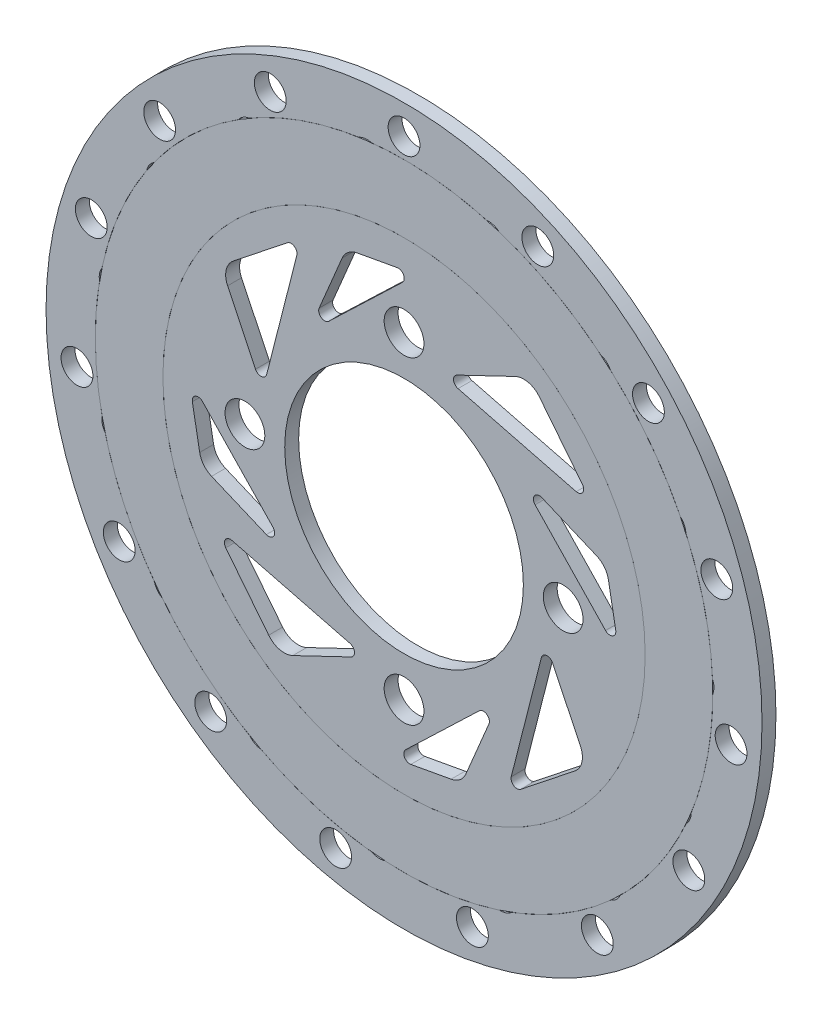
from build123d import *

# Parameters (mm, degrees)
SKETCH1_R                = 90
SKETCH1_R_2              = 30
SKETCH1_R_3              = 5
SKETCH1_R_4              = 4
SKETCH1_R_5              = 4.163878313
BOSS_EXTRUDE1_DEPTH      = 3.5
SKETCH3_R                = 77.611648898
SKETCH3_R_2              = 60.616629638
BOSS_EXTRUDE2_DEPTH      = 0.001
BOSS_EXTRUDE2_DEPTH_BACK = 3.501


with BuildPart() as part:
    # Sketch1 → Boss-Extrude1 (new body)
    with BuildSketch(Plane.XY):
        with Locations((-38.590160458, 20.233035518)):
            Circle(SKETCH1_R)
        with Locations((-38.590160458, 20.233035518)):
            Circle(SKETCH1_R_2, mode=Mode.SUBTRACT)
        with Locations((-38.590160458, 60.233035518)):
            Circle(SKETCH1_R_3, mode=Mode.SUBTRACT)
        with Locations((-78.590160458, 20.233035518)):
            Circle(SKETCH1_R_3, mode=Mode.SUBTRACT)
        with Locations((-38.590160458, -19.766964482)):
            Circle(SKETCH1_R_3, mode=Mode.SUBTRACT)
        with Locations((1.409839542, 20.233035518)):
            Circle(SKETCH1_R_3, mode=Mode.SUBTRACT)
        with Locations((-38.590160458, 102.908863271)):
            Circle(SKETCH1_R_4, mode=Mode.SUBTRACT)
        with Locations((-57.272235988, 84.226787741)):
            Circle(SKETCH1_R_5, mode=Mode.SUBTRACT)
        with Locations((-47.931198223, 93.567825506)):
            Circle(SKETCH1_R_4, mode=Mode.SUBTRACT)
        with Locations((-29.628481741, 86.292921865)):
            Circle(SKETCH1_R_5, mode=Mode.SUBTRACT)
        with Locations((-17.295676778, 91.027042142)):
            Circle(SKETCH1_R_4, mode=Mode.SUBTRACT)
        with Locations((-4.962871814, 95.761162419)):
            Circle(SKETCH1_R_4, mode=Mode.SUBTRACT)
        with Locations((-3.534283159, 76.936701505)):
            Circle(SKETCH1_R_5, mode=Mode.SUBTRACT)
        with Locations((9.657834985, 76.24533189)):
            Circle(SKETCH1_R_4, mode=Mode.SUBTRACT)
        with Locations((22.849953128, 75.553962274)):
            Circle(SKETCH1_R_4, mode=Mode.SUBTRACT)
        with Locations((16.498435766, 57.77590216)):
            Circle(SKETCH1_R_5, mode=Mode.SUBTRACT)
        with Locations((28.268830016, 51.778586739)):
            Circle(SKETCH1_R_4, mode=Mode.SUBTRACT)
        with Locations((40.039224266, 45.781271318)):
            Circle(SKETCH1_R_4, mode=Mode.SUBTRACT)
        with Locations((27.00583594, 32.123600105)):
            Circle(SKETCH1_R_5, mode=Mode.SUBTRACT)
        with Locations((35.3192982, 21.857329199)):
            Circle(SKETCH1_R_4, mode=Mode.SUBTRACT)
        with Locations((43.63276046, 11.591058294)):
            Circle(SKETCH1_R_4, mode=Mode.SUBTRACT)
        with Locations((26.171092415, 4.415311411)):
            Circle(SKETCH1_R_5, mode=Mode.SUBTRACT)
        with Locations((29.590149535, -8.344783474)):
            Circle(SKETCH1_R_4, mode=Mode.SUBTRACT)
        with Locations((33.009206655, -21.104878358)):
            Circle(SKETCH1_R_4, mode=Mode.SUBTRACT)
        with Locations((14.138539931, -20.557949085)):
            Circle(SKETCH1_R_5, mode=Mode.SUBTRACT)
        with Locations((12.072005874, -33.605531622)):
            Circle(SKETCH1_R_4, mode=Mode.SUBTRACT)
        with Locations((10.005471816, -46.653114158)):
            Circle(SKETCH1_R_4, mode=Mode.SUBTRACT)
        with Locations((-7.011283875, -38.478077769)):
            Circle(SKETCH1_R_5, mode=Mode.SUBTRACT)
        with Locations((-14.206086598, -49.557102403)):
            Circle(SKETCH1_R_4, mode=Mode.SUBTRACT)
        with Locations((-21.40088932, -60.636127037)):
            Circle(SKETCH1_R_4, mode=Mode.SUBTRACT)
        with Locations((-33.621382328, -46.246521592)):
            Circle(SKETCH1_R_5, mode=Mode.SUBTRACT)
        with Locations((-44.700406962, -53.441324315)):
            Circle(SKETCH1_R_4, mode=Mode.SUBTRACT)
        with Locations((-55.779431596, -60.636127037)):
            Circle(SKETCH1_R_4, mode=Mode.SUBTRACT)
        with Locations((-61.090627659, -42.520046043)):
            Circle(SKETCH1_R_5, mode=Mode.SUBTRACT)
        with Locations((-74.138210196, -44.5865801)):
            Circle(SKETCH1_R_4, mode=Mode.SUBTRACT)
        with Locations((-87.185792732, -46.653114158)):
            Circle(SKETCH1_R_4, mode=Mode.SUBTRACT)
        with Locations((-84.669337801, -27.942992598)):
            Circle(SKETCH1_R_5, mode=Mode.SUBTRACT)
        with Locations((-97.429432686, -24.523935478)):
            Circle(SKETCH1_R_4, mode=Mode.SUBTRACT)
        with Locations((-110.189527571, -21.104878358)):
            Circle(SKETCH1_R_4, mode=Mode.SUBTRACT)
        with Locations((-100.280539565, -5.035866226)):
            Circle(SKETCH1_R_5, mode=Mode.SUBTRACT)
        with Locations((-110.54681047, 3.277596034)):
            Circle(SKETCH1_R_4, mode=Mode.SUBTRACT)
        with Locations((-120.813081376, 11.591058294)):
            Circle(SKETCH1_R_4, mode=Mode.SUBTRACT)
        with Locations((-105.224914341, 22.240482818)):
            Circle(SKETCH1_R_5, mode=Mode.SUBTRACT)
        with Locations((-111.222229762, 34.010877068)):
            Circle(SKETCH1_R_4, mode=Mode.SUBTRACT)
        with Locations((-117.219545183, 45.781271318)):
            Circle(SKETCH1_R_4, mode=Mode.SUBTRACT)
        with Locations((-98.647534813, 49.169725987)):
            Circle(SKETCH1_R_5, mode=Mode.SUBTRACT)
        with Locations((-99.338904429, 62.36184413)):
            Circle(SKETCH1_R_4, mode=Mode.SUBTRACT)
        with Locations((-100.030274045, 75.553962274)):
            Circle(SKETCH1_R_4, mode=Mode.SUBTRACT)
        with Locations((-81.685689655, 71.095552492)):
            Circle(SKETCH1_R_5, mode=Mode.SUBTRACT)
        with Locations((-76.951569379, 83.428357455)):
            Circle(SKETCH1_R_4, mode=Mode.SUBTRACT)
        with Locations((-72.217449102, 95.761162419)):
            Circle(SKETCH1_R_4, mode=Mode.SUBTRACT)
        with BuildLine():
            Line((-75.923250233, 33.526611773), (-82.945064437, 48.18024702))
            ThreePointArc((-82.945064437, 48.18024702), (-83.308109154, 51.464629536), (-81.543225165, 54.258221219))
            Line((-81.543225165, 54.258221219), (-67.922632883, 65.062083457))
            ThreePointArc((-67.922632883, 65.062083457), (-66.174715863, 65.145679261), (-65.537023858, 63.516093095))
            Line((-65.537023858, 63.516093095), (-73.117089427, 33.80401367))
            ThreePointArc((-73.117089427, 33.80401367), (-74.422973645, 32.682089003), (-75.923250233, 33.526611773))
        make_face(mode=Mode.SUBTRACT)
        with BuildLine():
            Line((-25.019182306, 54.759964487), (4.692897118, 47.179898918))
            ThreePointArc((4.692897118, 47.179898918), (6.322483285, 47.817590922), (6.238887481, 49.565507943))
            Line((6.238887481, 49.565507943), (-4.564974758, 63.186100225))
            ThreePointArc((-4.564974758, 63.186100225), (-7.35856644, 64.950984214), (-10.642948957, 64.587939497))
            Line((-10.642948957, 64.587939497), (-25.296584204, 57.566125293))
            ThreePointArc((-25.296584204, 57.566125293), (-26.141106973, 56.065848705), (-25.019182306, 54.759964487))
        make_face(mode=Mode.SUBTRACT)
        with BuildLine():
            Line((-4.06323149, 6.662057366), (-11.643297059, -23.050022058))
            ThreePointArc((-11.643297059, -23.050022058), (-11.005605054, -24.679608225), (-9.257688034, -24.596012421))
            Line((-9.257688034, -24.596012421), (4.362904249, -13.792150183))
            ThreePointArc((4.362904249, -13.792150183), (6.127788237, -10.9985585), (5.764743521, -7.714175984))
            Line((5.764743521, -7.714175984), (-1.257070683, 6.939459263))
            ThreePointArc((-1.257070683, 6.939459263), (-2.757347272, 7.783982033), (-4.06323149, 6.662057366))
        make_face(mode=Mode.SUBTRACT)
        with BuildLine():
            Line((-52.16113861, -14.29389345), (-81.873218035, -6.713827882))
            ThreePointArc((-81.873218035, -6.713827882), (-83.502804202, -7.351519886), (-83.419208397, -9.099436907))
            Line((-83.419208397, -9.099436907), (-72.615346159, -22.720029189))
            ThreePointArc((-72.615346159, -22.720029189), (-69.821754476, -24.484913178), (-66.53737196, -24.121868461))
            Line((-66.53737196, -24.121868461), (-51.883736713, -17.100054257))
            ThreePointArc((-51.883736713, -17.100054257), (-51.039213944, -15.599777669), (-52.16113861, -14.29389345))
        make_face(mode=Mode.SUBTRACT)
        with BuildLine():
            Line((-50.430809264, 71.604828983), (-40.306353074, 73.454044222))
            ThreePointArc((-40.306353074, 73.454044222), (-38.700938161, 72.66063457), (-38.999542003, 70.894935936))
            Line((-38.999542003, 70.894935936), (-57.510335459, 53.1738017))
            ThreePointArc((-57.510335459, 53.1738017), (-59.397534082, 53.021332689), (-59.930645054, 54.838076517))
            Line((-59.930645054, 54.838076517), (-54.14247101, 68.622050752))
            ThreePointArc((-54.14247101, 68.622050752), (-52.664508346, 70.58364545), (-50.430809264, 71.604828983))
        make_face(mode=Mode.SUBTRACT)
        with BuildLine():
            Line((12.781633006, 32.073684324), (14.630848245, 21.949228134))
            ThreePointArc((14.630848245, 21.949228134), (13.837438594, 20.34381322), (12.07173996, 20.642417062))
            Line((12.07173996, 20.642417062), (-5.649394276, 39.153210519))
            ThreePointArc((-5.649394276, 39.153210519), (-5.801863288, 41.040409142), (-3.98511946, 41.573520114))
            Line((-3.98511946, 41.573520114), (9.798854776, 35.78534607))
            ThreePointArc((9.798854776, 35.78534607), (11.760449474, 34.307383406), (12.781633006, 32.073684324))
        make_face(mode=Mode.SUBTRACT)
        with BuildLine():
            Line((-26.749511652, -31.138757947), (-36.873967842, -32.987973185))
            ThreePointArc((-36.873967842, -32.987973185), (-38.479382756, -32.194563534), (-38.180778914, -30.4288649))
            Line((-38.180778914, -30.4288649), (-19.669985458, -12.707730664))
            ThreePointArc((-19.669985458, -12.707730664), (-17.782786834, -12.555261653), (-17.249675862, -14.372005481))
            Line((-17.249675862, -14.372005481), (-23.037849906, -28.155979716))
            ThreePointArc((-23.037849906, -28.155979716), (-24.51581257, -30.117574414), (-26.749511652, -31.138757947))
        make_face(mode=Mode.SUBTRACT)
        with BuildLine():
            Line((-89.961953923, 8.392386712), (-91.811169162, 18.516842902))
            ThreePointArc((-91.811169162, 18.516842902), (-91.01775951, 20.122257816), (-89.252060876, 19.823653974))
            Line((-89.252060876, 19.823653974), (-71.53092664, 1.312860518))
            ThreePointArc((-71.53092664, 1.312860518), (-71.378457629, -0.574338106), (-73.195201457, -1.107449078))
            Line((-73.195201457, -1.107449078), (-86.979175693, 4.680724966))
            ThreePointArc((-86.979175693, 4.680724966), (-88.940770391, 6.15868763), (-89.961953923, 8.392386712))
        make_face(mode=Mode.SUBTRACT)
    extrude(amount=BOSS_EXTRUDE1_DEPTH)

    # Sketch3 → Boss-Extrude2 (add, two sides)
    with BuildSketch(Plane(origin=(0, 0, 0), x_dir=(-1, 0, 0), z_dir=(0, 0, -1))) as boss_extrude2_sk:
        with Locations((38.590160458, 20.233035518)):
            Circle(SKETCH3_R)
        with Locations((38.590160458, 20.233035518)):
            Circle(SKETCH3_R_2, mode=Mode.SUBTRACT)
    extrude(amount=BOSS_EXTRUDE2_DEPTH)
    extrude(boss_extrude2_sk.sketch, amount=-BOSS_EXTRUDE2_DEPTH_BACK)


solid = part.part
